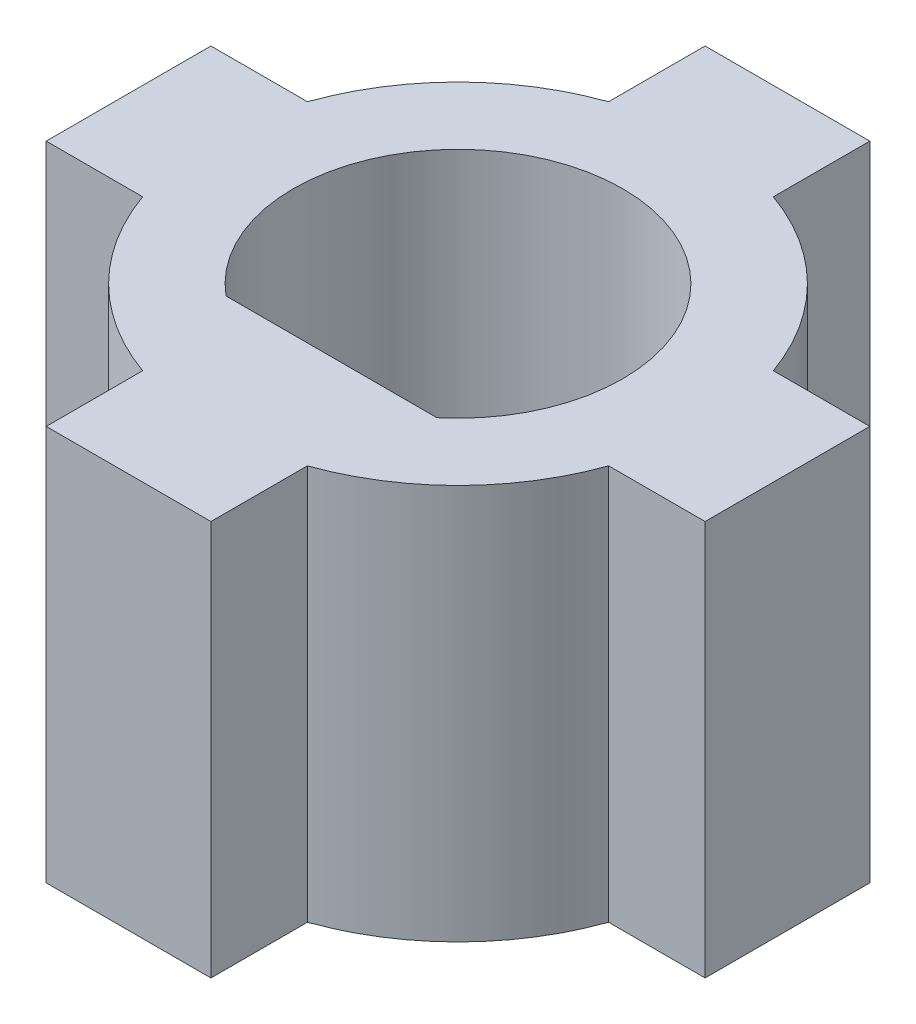
from build123d import *

# Parameters (mm, degrees)
BOSS_EXTRUDE3_DEPTH = 7.62


with BuildPart() as part:
    # Sketch3 → Boss-Extrude3 (new body)
    with BuildSketch(Plane(origin=(0, 0, 0), x_dir=(1, 0, 0), z_dir=(0, 1, 0))):
        with BuildLine():
            ThreePointArc((-1.5875, 4.490128061), (0, 4.7625), (1.5875, 4.490128061))
            Line((1.5875, 4.490128061), (1.5875, 6.35))
            Line((1.5875, 6.35), (-1.5875, 6.35))
            Line((-1.5875, 6.35), (-1.5875, 4.490128061))
        make_face()
        with BuildLine():
            Line((-6.35, -1.5875), (-4.490128061, -1.5875))
            ThreePointArc((-4.490128061, -1.5875), (-4.7625, 0), (-4.490128061, 1.5875))
            Line((-4.490128061, 1.5875), (-6.35, 1.5875))
            Line((-6.35, 1.5875), (-6.35, -1.5875))
        make_face()
        with BuildLine():
            Line((-4.490128061, 1.5875), (-2.749630657, 1.5875))
            ThreePointArc((-2.749630657, 1.5875), (-2.24506403, 2.24506403), (-1.5875, 2.749630657))
            Line((-1.5875, 2.749630657), (-1.5875, 4.490128061))
            ThreePointArc((-1.5875, 4.490128061), (-3.367596045, 3.367596045), (-4.490128061, 1.5875))
        make_face()
        with BuildLine():
            Line((-4.490128061, -1.5875), (-2.749630657, -1.5875))
            ThreePointArc((-2.749630657, -1.5875), (-3.175, 0), (-2.749630657, 1.5875))
            Line((-2.749630657, 1.5875), (-4.490128061, 1.5875))
            ThreePointArc((-4.490128061, 1.5875), (-4.7625, 0), (-4.490128061, -1.5875))
        make_face()
        with BuildLine():
            ThreePointArc((-1.5875, 2.749630657), (0, 3.175), (1.5875, 2.749630657))
            Line((1.5875, 2.749630657), (1.5875, 4.490128061))
            ThreePointArc((1.5875, 4.490128061), (0, 4.7625), (-1.5875, 4.490128061))
            Line((-1.5875, 4.490128061), (-1.5875, 2.749630657))
        make_face()
        with BuildLine():
            ThreePointArc((1.5875, 2.749630657), (2.24506403, 2.24506403), (2.749630657, 1.5875))
            Line((2.749630657, 1.5875), (4.490128061, 1.5875))
            ThreePointArc((4.490128061, 1.5875), (3.367596045, 3.367596045), (1.5875, 4.490128061))
            Line((1.5875, 4.490128061), (1.5875, 2.749630657))
        make_face()
        with BuildLine():
            ThreePointArc((4.7625, 0), (4.69391314, -0.805348174), (4.490128061, -1.5875))
            Line((4.490128061, -1.5875), (6.35, -1.5875))
            Line((6.35, -1.5875), (6.35, 1.5875))
            Line((6.35, 1.5875), (4.490128061, 1.5875))
            ThreePointArc((4.490128061, 1.5875), (4.69391314, 0.805348174), (4.7625, 0))
        make_face()
        with BuildLine():
            ThreePointArc((3.175, 0), (3.066814498, -0.821750468), (2.749630657, -1.5875))
            Line((2.749630657, -1.5875), (4.490128061, -1.5875))
            ThreePointArc((4.490128061, -1.5875), (4.69391314, -0.805348174), (4.7625, 0))
            ThreePointArc((4.7625, 0), (4.69391314, 0.805348174), (4.490128061, 1.5875))
            Line((4.490128061, 1.5875), (2.749630657, 1.5875))
            ThreePointArc((2.749630657, 1.5875), (3.066814498, 0.821750468), (3.175, 0))
        make_face()
        with BuildLine():
            Line((-1.5875, -4.490128061), (-1.5875, -2.749630657))
            ThreePointArc((-1.5875, -2.749630657), (-1.81637725, -2.604111881), (-2.032, -2.439590334))
            ThreePointArc((-2.032, -2.439590334), (-2.428479446, -2.045265895), (-2.749630657, -1.5875))
            Line((-2.749630657, -1.5875), (-4.490128061, -1.5875))
            ThreePointArc((-4.490128061, -1.5875), (-3.367596045, -3.367596045), (-1.5875, -4.490128061))
        make_face()
        with BuildLine():
            Line((-1.5875, -2.749630657), (-1.5875, -2.439590334))
            Line((-1.5875, -2.439590334), (-2.032, -2.439590334))
            ThreePointArc((-2.032, -2.439590334), (-1.81637725, -2.604111881), (-1.5875, -2.749630657))
        make_face()
        with BuildLine():
            Line((1.5875, -2.749630657), (1.5875, -2.439590334))
            Line((1.5875, -2.439590334), (-1.5875, -2.439590334))
            Line((-1.5875, -2.439590334), (-1.5875, -2.749630657))
            ThreePointArc((-1.5875, -2.749630657), (0, -3.175), (1.5875, -2.749630657))
        make_face()
        with BuildLine():
            ThreePointArc((1.5875, -2.749630657), (1.81637725, -2.604111881), (2.032, -2.439590334))
            Line((2.032, -2.439590334), (1.5875, -2.439590334))
            Line((1.5875, -2.439590334), (1.5875, -2.749630657))
        make_face()
        with BuildLine():
            ThreePointArc((2.749630657, -1.5875), (2.428479446, -2.045265895), (2.032, -2.439590334))
            ThreePointArc((2.032, -2.439590334), (1.81637725, -2.604111881), (1.5875, -2.749630657))
            Line((1.5875, -2.749630657), (1.5875, -4.490128061))
            ThreePointArc((1.5875, -4.490128061), (3.367596045, -3.367596045), (4.490128061, -1.5875))
            Line((4.490128061, -1.5875), (2.749630657, -1.5875))
        make_face()
        with BuildLine():
            Line((1.5875, -4.490128061), (1.5875, -2.749630657))
            ThreePointArc((1.5875, -2.749630657), (0, -3.175), (-1.5875, -2.749630657))
            Line((-1.5875, -2.749630657), (-1.5875, -4.490128061))
            ThreePointArc((-1.5875, -4.490128061), (0, -4.7625), (1.5875, -4.490128061))
        make_face()
        with BuildLine():
            Line((1.5875, -6.35), (1.5875, -4.490128061))
            ThreePointArc((1.5875, -4.490128061), (0, -4.7625), (-1.5875, -4.490128061))
            Line((-1.5875, -4.490128061), (-1.5875, -6.35))
            Line((-1.5875, -6.35), (1.5875, -6.35))
        make_face()
    extrude(amount=BOSS_EXTRUDE3_DEPTH)


solid = part.part
